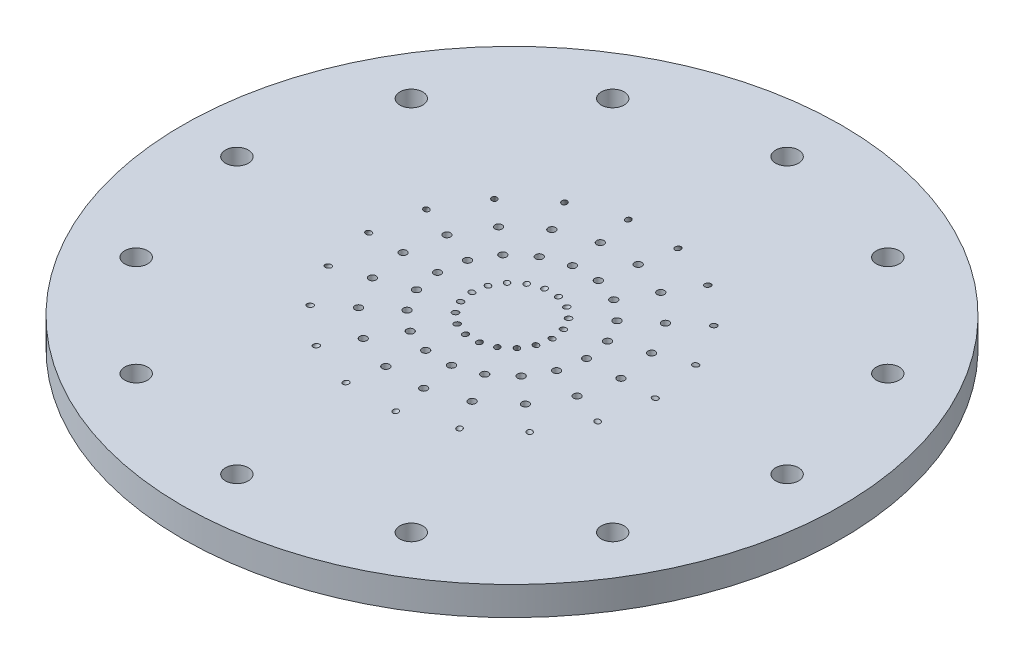
from build123d import *

# Parameters (mm, degrees)
SKETCH1_R           = 73.025
BOSS_EXTRUDE1_DEPTH = 6.35
SKETCH4_R           = 0.59055
CUT_EXTRUDE1_DEPTH  = 50.8475
CUT_EXTRUDE2_START  = -53.3875
SKETCH6_R           = 0.59055
CUT_EXTRUDE2_DEPTH  = 80.524261314
LOX_START           = -7.35
SKETCH7_R           = 0.80645
LOX_HOLES_DEPTH     = 8.35
CIRPATTERN1_COUNT   = 18
SKETCH8_R           = 2.54
CUT_EXTRUDE4_DEPTH  = 7.35
CIRPATTERN2_COUNT   = 12


with BuildPart() as part:
    # Sketch1 → Boss-Extrude1 (new body)
    with BuildSketch(Plane(origin=(0, 0, 0), x_dir=(1, 0, 0), z_dir=(0, 1, 0))):
        Circle(SKETCH1_R)
    extrude(amount=BOSS_EXTRUDE1_DEPTH)

    # Sketch4 → Cut-Extrude1 (cut, through all)
    with BuildSketch(Plane(origin=(-3.917869343, -6.785948759, 0), x_dir=(-0.866025404, 0.5, 0), z_dir=(0.5, 0.866025404, 0))):
        with Locations((-4.52396584, 0)):
            Circle(SKETCH4_R)
    cut_extrude1 = extrude(amount=CUT_EXTRUDE1_DEPTH, mode=Mode.SUBTRACT)

    # Sketch6 → Cut-Extrude2 (cut)
    with BuildSketch(Plane(origin=(5.187869343, -8.985653285, 0), x_dir=(0.866025404, 0.5, 0), z_dir=(0.5, -0.866025404, 0)).offset(CUT_EXTRUDE2_START)):
        with Locations((30.67130657, 0)):
            Circle(SKETCH6_R)
    cut_extrude2 = extrude(amount=CUT_EXTRUDE2_DEPTH, mode=Mode.SUBTRACT)

    # Sketch7 → LOx Holes (cut)
    with BuildSketch(Plane(origin=(0, 6.35, 0), x_dir=(1, 0, 0), z_dir=(0, 1, 0)).offset(LOX_START)):
        with Locations((24.13, 0)):
            Circle(SKETCH7_R)
        with Locations((16.51, 0)):
            Circle(SKETCH7_R)
    lox_holes = extrude(amount=LOX_HOLES_DEPTH, mode=Mode.SUBTRACT)

    # CirPattern1: Cut-Extrude1, Cut-Extrude2, LOx Holes ×18 about axis
    cirpattern1_axis = Axis((0, 0, 0), (0, 1, 0))
    for i in range(1, CIRPATTERN1_COUNT):
        add(cut_extrude1.rotate(cirpattern1_axis, i * 360 / CIRPATTERN1_COUNT), mode=Mode.SUBTRACT)
        add(cut_extrude2.rotate(cirpattern1_axis, i * 360 / CIRPATTERN1_COUNT), mode=Mode.SUBTRACT)
        add(lox_holes.rotate(cirpattern1_axis, i * 360 / CIRPATTERN1_COUNT), mode=Mode.SUBTRACT)

    # Sketch8 → Cut-Extrude4 (cut, through all)
    with BuildSketch(Plane.XZ):
        with Locations((-60.96, 0)):
            Circle(SKETCH8_R)
    cut_extrude4 = extrude(amount=-CUT_EXTRUDE4_DEPTH, mode=Mode.SUBTRACT)

    # CirPattern2: Cut-Extrude4 ×12 about axis
    cirpattern2_axis = Axis((0, 0, 0), (0, 1, 0))
    for i in range(1, CIRPATTERN2_COUNT):
        add(cut_extrude4.rotate(cirpattern2_axis, i * 360 / CIRPATTERN2_COUNT), mode=Mode.SUBTRACT)


solid = part.part
